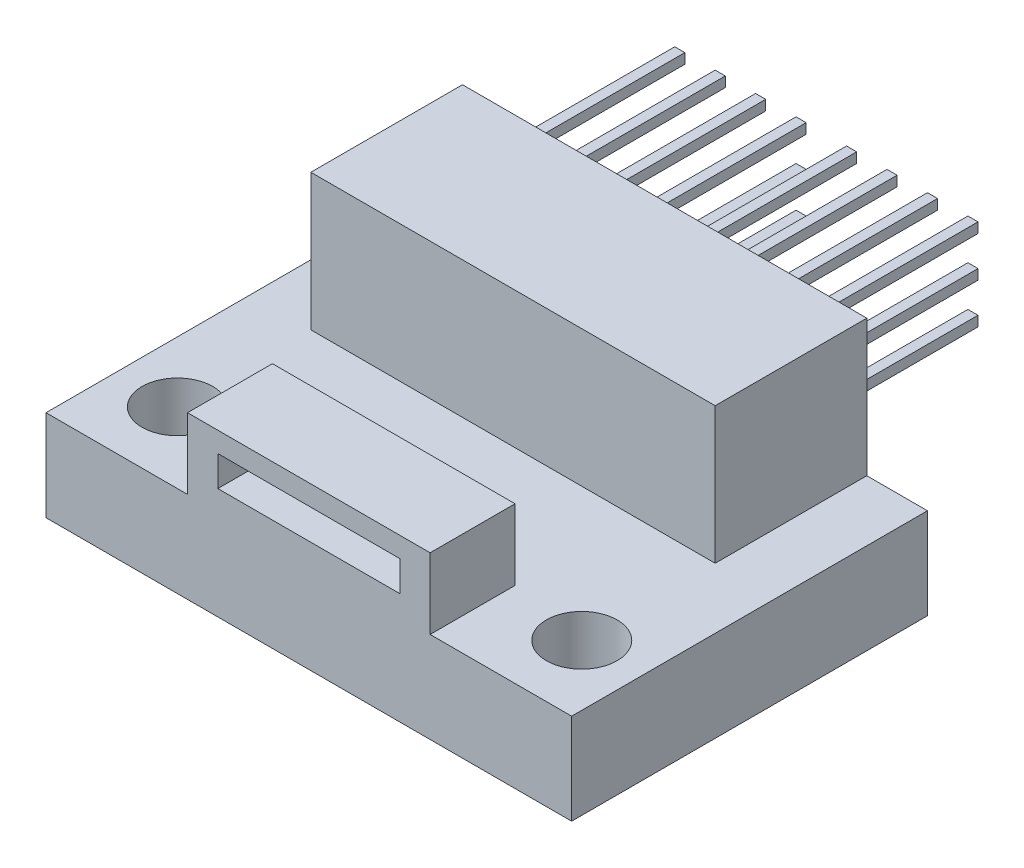
from build123d import *

# Parameters (mm, degrees)
SKETCH1_W           = 26
SKETCH1_H           = 17.6
SKETCH1_R           = 1.75
BOSS_EXTRUDE1_DEPTH = 4.5
SKETCH2_W           = 12
SKETCH2_H           = 4.2
BOSS_EXTRUDE2_DEPTH = 3.5
SKETCH3_W           = 9
SKETCH3_H           = 1.5
CUT_EXTRUDE1_DEPTH  = 1.5
SKETCH4_W           = 20
SKETCH4_H           = 7.5
BOSS_EXTRUDE3_DEPTH = 6.75
SKETCH5_W           = 0.5
SKETCH5_H           = 0.5
BOSS_EXTRUDE4_DEPTH = 8


with BuildPart() as part:
    # Sketch1 → Boss-Extrude1 (new body)
    with BuildSketch(Plane(origin=(0, 0, 0), x_dir=(1, 0, 0), z_dir=(0, 1, 0))):
        Rectangle(SKETCH1_W, SKETCH1_H)
        with Locations((10, -5.3)):
            Circle(SKETCH1_R, mode=Mode.SUBTRACT)
        with Locations((-10, -5.3)):
            Circle(SKETCH1_R, mode=Mode.SUBTRACT)
    extrude(amount=BOSS_EXTRUDE1_DEPTH)

    # Sketch2 → Boss-Extrude2 (add)
    with BuildSketch(Plane(origin=(0, 4.5, 0), x_dir=(1, 0, 0), z_dir=(0, 1, 0))):
        with Locations((0, -6.7)):
            Rectangle(SKETCH2_W, SKETCH2_H)
    extrude(amount=BOSS_EXTRUDE2_DEPTH)

    # Sketch3 → Cut-Extrude1 (cut)
    with BuildSketch(Plane.XY.offset(8.8)):
        with Locations((0, 6.25)):
            Rectangle(SKETCH3_W, SKETCH3_H)
    extrude(amount=-CUT_EXTRUDE1_DEPTH, mode=Mode.SUBTRACT)

    # Sketch4 → Boss-Extrude3 (add)
    with BuildSketch(Plane(origin=(0, 4.5, 0), x_dir=(1, 0, 0), z_dir=(0, 1, 0))):
        with Locations((0, 5.05)):
            Rectangle(SKETCH4_W, SKETCH4_H)
    extrude(amount=BOSS_EXTRUDE3_DEPTH)

    # Sketch5 → Boss-Extrude4 (add)
    with BuildSketch(Plane(origin=(0, 0, -8.8), x_dir=(-1, 0, 0), z_dir=(0, 0, -1))):
        with Locations((3.25, 7.875)):
            Rectangle(SKETCH5_W, SKETCH5_H)
        with Locations((1.25, 7.875)):
            Rectangle(SKETCH5_W, SKETCH5_H)
        with Locations((5.25, 7.875)):
            Rectangle(SKETCH5_W, SKETCH5_H)
        with Locations((7.25, 7.875)):
            Rectangle(SKETCH5_W, SKETCH5_H)
        with Locations((-7.25, 7.875)):
            Rectangle(SKETCH5_W, SKETCH5_H)
        with Locations((-5.25, 7.875)):
            Rectangle(SKETCH5_W, SKETCH5_H)
        with Locations((-3.25, 7.875)):
            Rectangle(SKETCH5_W, SKETCH5_H)
        with Locations((-1.25, 7.875)):
            Rectangle(SKETCH5_W, SKETCH5_H)
        with Locations((-3.25, 9.875)):
            Rectangle(SKETCH5_W, SKETCH5_H)
        with Locations((-1.25, 9.875)):
            Rectangle(SKETCH5_W, SKETCH5_H)
        with Locations((-5.25, 9.875)):
            Rectangle(SKETCH5_W, SKETCH5_H)
        with Locations((-7.25, 9.875)):
            Rectangle(SKETCH5_W, SKETCH5_H)
        with Locations((7.25, 9.875)):
            Rectangle(SKETCH5_W, SKETCH5_H)
        with Locations((5.25, 9.875)):
            Rectangle(SKETCH5_W, SKETCH5_H)
        with Locations((3.25, 9.875)):
            Rectangle(SKETCH5_W, SKETCH5_H)
        with Locations((1.25, 9.875)):
            Rectangle(SKETCH5_W, SKETCH5_H)
        with Locations((-3.25, 5.875)):
            Rectangle(SKETCH5_W, SKETCH5_H)
        with Locations((-1.25, 5.875)):
            Rectangle(SKETCH5_W, SKETCH5_H)
        with Locations((-5.25, 5.875)):
            Rectangle(SKETCH5_W, SKETCH5_H)
        with Locations((-7.25, 5.875)):
            Rectangle(SKETCH5_W, SKETCH5_H)
        with Locations((7.25, 5.875)):
            Rectangle(SKETCH5_W, SKETCH5_H)
        with Locations((5.25, 5.875)):
            Rectangle(SKETCH5_W, SKETCH5_H)
        with Locations((3.25, 5.875)):
            Rectangle(SKETCH5_W, SKETCH5_H)
        with Locations((1.25, 5.875)):
            Rectangle(SKETCH5_W, SKETCH5_H)
    extrude(amount=BOSS_EXTRUDE4_DEPTH)


solid = part.part
